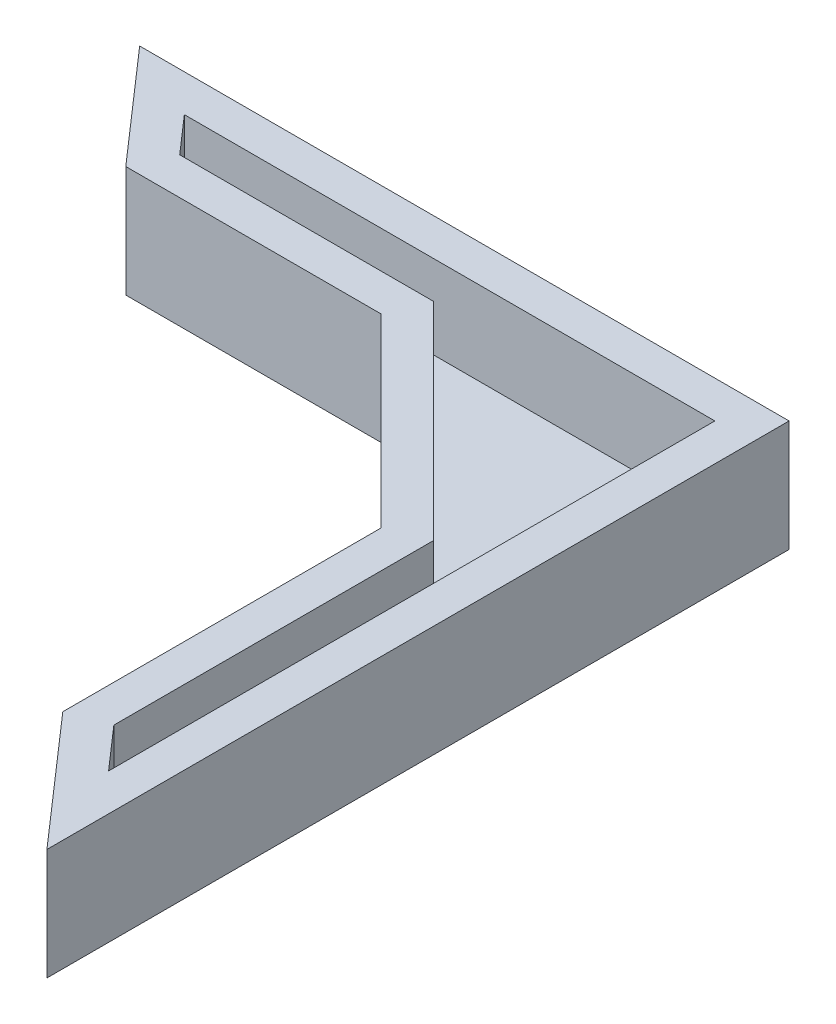
from build123d import *

# Parameters (mm, degrees)
EXTRUDE_1_DEPTH     = 6
CUT_EXTRUDE_1_DEPTH = 4.5


with BuildPart() as part:
    # 草图1 → 凸台-拉伸1 (new body)
    with BuildSketch(Plane(origin=(0, 0, 0), x_dir=(1, 0, 0), z_dir=(0, 1, 0))):
        Polygon((-35, 0), (0, 0), (0, -40), (-6, -33.142857143), (-6, -16), (-16, -6), (-29.75, -6), align=None)
    extrude(amount=EXTRUDE_1_DEPTH)

    # 草图3 → 切除-拉伸1 (cut)
    with BuildSketch(Plane(origin=(0, 6, 0), x_dir=(1, 0, 0), z_dir=(0, 1, 0))):
        Polygon((-30.592463547, -2), (-28.842463547, -4), (-15.171572875, -4), (-4, -15.171572875), (-4, -32.391386911), (-2, -34.677101196), (-2, -2), align=None)
    extrude(amount=-CUT_EXTRUDE_1_DEPTH, mode=Mode.SUBTRACT)


solid = part.part
